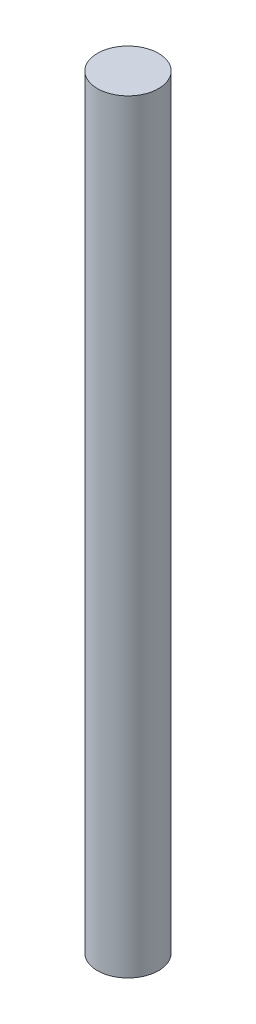
from build123d import *

# Parameters (mm, degrees)
CROQUIS1_R              = 4
SALIENTE_EXTRUIR1_DEPTH = 100


with BuildPart() as part:
    # Croquis1 → Saliente-Extruir1 (new body)
    with BuildSketch(Plane(origin=(0, 0, 0), x_dir=(1, 0, 0), z_dir=(0, 1, 0))):
        Circle(CROQUIS1_R)
    extrude(amount=SALIENTE_EXTRUIR1_DEPTH)


solid = part.part
